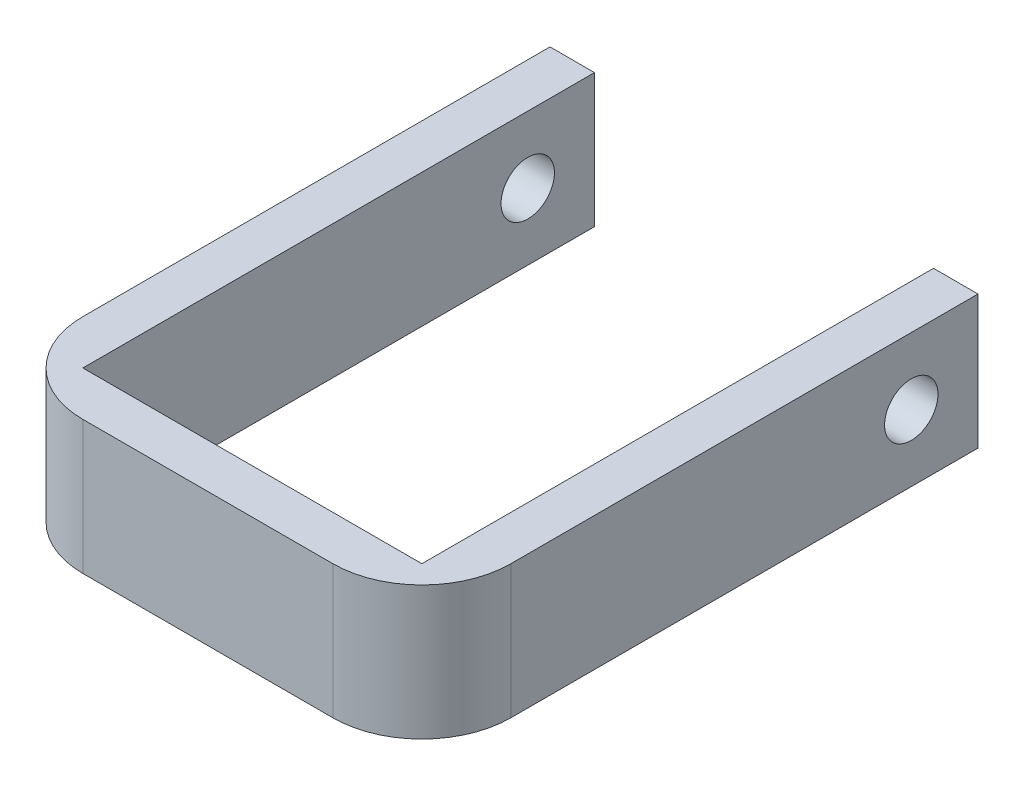
from build123d import *

# Parameters (mm, degrees)
BOSS_EXTRUDE1_DEPTH = 30
FILLET1_R           = 20
SKETCH2_R           = 6
CUT_EXTRUDE1_DEPTH  = 97.2


with BuildPart() as part:
    # Sketch1 → Boss-Extrude1 (new body)
    with BuildSketch(Plane(origin=(0, 0, 0), x_dir=(1, 0, 0), z_dir=(0, 1, 0))):
        Polygon((0, 115), (-10, 115), (-10, -10), (86.2, -10), (86.2, 115), (76.2, 115), (76.2, 0), (0, 0), align=None)
    extrude(amount=BOSS_EXTRUDE1_DEPTH)

    # Fillet1
    fillet1_edges = [part.edges().sort_by_distance(p)[0] for p in [
        (86.2, 15, 10),
        (-10, 15, 10),
    ]]
    fillet(fillet1_edges, radius=FILLET1_R)

    # Sketch2 → Cut-Extrude1 (cut, through all)
    with BuildSketch(Plane(origin=(86.2, 0, 0), x_dir=(0, 0, -1), z_dir=(1, 0, 0))):
        with Locations((100, 15)):
            Circle(SKETCH2_R)
    extrude(amount=-CUT_EXTRUDE1_DEPTH, mode=Mode.SUBTRACT)


solid = part.part
